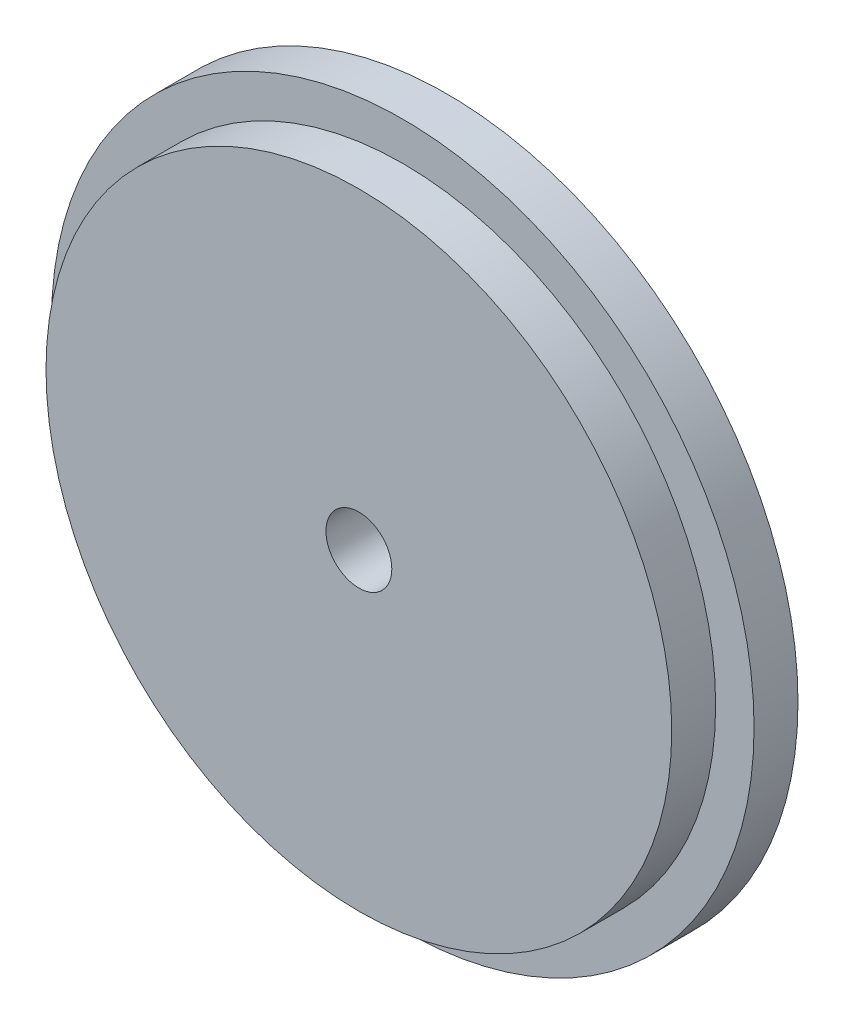
from build123d import *

# Parameters (mm, degrees)
ESQUISSE1_R             = 16
BOSS_EXTRU_1_DEPTH      = 2
ESQUISSE2_R             = 14.25
BOSS_EXTRU_2_DEPTH      = 2
ESQUISSE3_R             = 1.5
ENL_V_MAT_EXTRU_1_DEPTH = 5


with BuildPart() as part:
    # Esquisse1 → Boss.-Extru.1 (new body)
    with BuildSketch(Plane.XY):
        Circle(ESQUISSE1_R)
    extrude(amount=BOSS_EXTRU_1_DEPTH)

    # Esquisse2 → Boss.-Extru.2 (add)
    with BuildSketch(Plane.XY.offset(2)):
        Circle(ESQUISSE2_R)
    extrude(amount=BOSS_EXTRU_2_DEPTH)

    # Esquisse3 → Enlèv. mat.-Extru.1 (cut, through all)
    with BuildSketch(Plane.XY.offset(4)):
        Circle(ESQUISSE3_R)
    extrude(amount=-ENL_V_MAT_EXTRU_1_DEPTH, mode=Mode.SUBTRACT)


solid = part.part
